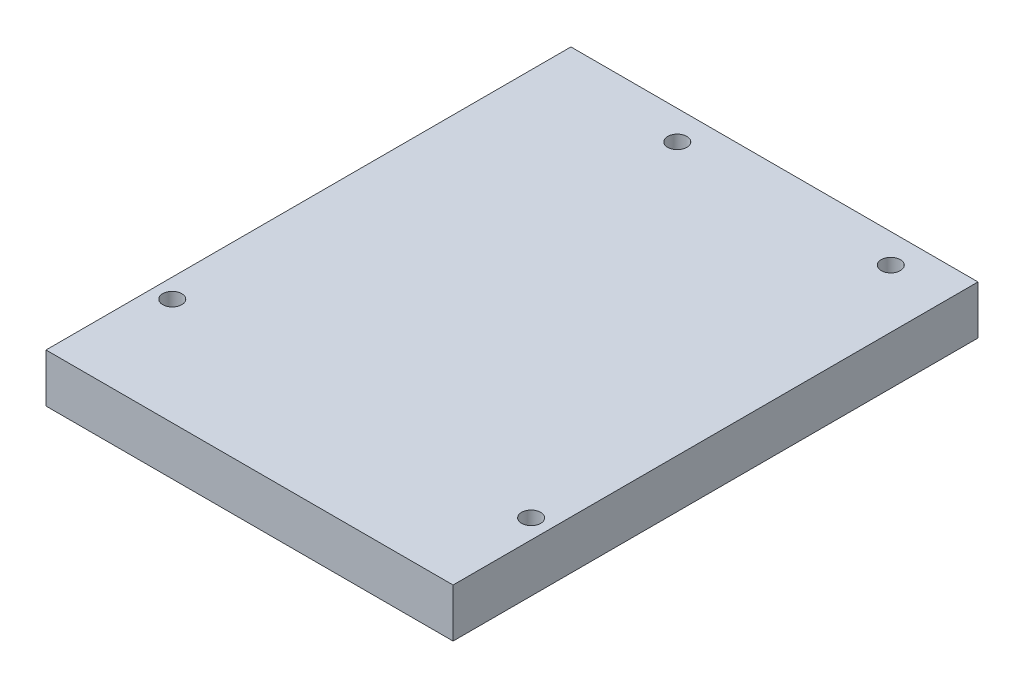
from build123d import *

# Parameters (mm, degrees)
SKETCH1_W           = 53.2
SKETCH1_H           = 68.6
SKETCH1_R           = 1.25
BOSS_EXTRUDE1_DEPTH = 6.35


with BuildPart() as part:
    # Sketch1 → Boss-Extrude1 (new body)
    with BuildSketch(Plane(origin=(0, 0, 0), x_dir=(1, 0, 0), z_dir=(0, 1, 0))):
        with Locations((-26.6, 34.3)):
            Rectangle(SKETCH1_W, SKETCH1_H)
        with Locations((-35.5, 64.8)):
            Circle(SKETCH1_R, mode=Mode.SUBTRACT)
        with Locations((-7.6, 64.8)):
            Circle(SKETCH1_R, mode=Mode.SUBTRACT)
        with Locations((-50.7, 14)):
            Circle(SKETCH1_R, mode=Mode.SUBTRACT)
        with Locations((-2.5, 12.7)):
            Circle(SKETCH1_R, mode=Mode.SUBTRACT)
    extrude(amount=BOSS_EXTRUDE1_DEPTH)


solid = part.part
